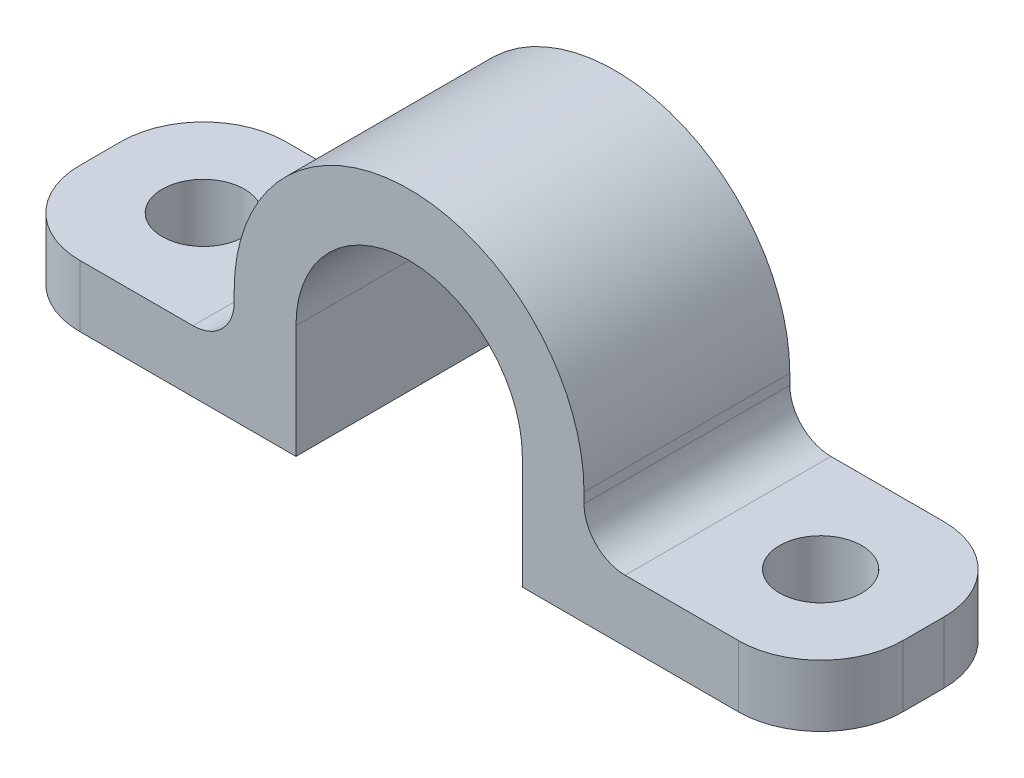
from build123d import *

# Parameters (mm, degrees)
BOSS_EXTRUDE1_DEPTH = 5
SKETCH2_R           = 2
CUT_EXTRUDE1_DEPTH  = 4
FILLET1_R           = 4
FILLET2_R           = 2


with BuildPart() as part:
    # Sketch1 → Boss-Extrude1 (new body, symmetric)
    with BuildSketch(Plane.XY):
        with BuildLine():
            Line((-5.5, -2.5), (-5.5, 0))
            ThreePointArc((-5.5, 0), (0, 5.5), (5.5, 0))
            Line((5.5, 0), (5.5, -2.5))
            Line((5.5, -2.5), (8.124038405, -2.5))
            ThreePointArc((8.124038405, -2.5), (8.405484116, -1.264055687), (8.5, 0))
            ThreePointArc((8.5, 0), (0, 8.5), (-8.5, 0))
            ThreePointArc((-8.5, 0), (-8.405484116, -1.264055687), (-8.124038405, -2.5))
            Line((-8.124038405, -2.5), (-5.5, -2.5))
        make_face()
        with BuildLine():
            Line((-5.5, -5.5), (-5.5, -2.5))
            Line((-5.5, -2.5), (-8.124038405, -2.5))
            ThreePointArc((-8.124038405, -2.5), (-7.454857018, -4.083516479), (-6.480740698, -5.5))
            Line((-6.480740698, -5.5), (-5.5, -5.5))
        make_face()
        with BuildLine():
            ThreePointArc((-6.480740698, -5.5), (-7.454857018, -4.083516479), (-8.124038405, -2.5))
            Line((-8.124038405, -2.5), (-8.5, -2.5))
            Line((-8.5, -2.5), (-20, -2.5))
            Line((-20, -2.5), (-20, -5.5))
            Line((-20, -5.5), (-6.480740698, -5.5))
        make_face()
        with BuildLine():
            Line((8.124038405, -2.5), (5.5, -2.5))
            Line((5.5, -2.5), (5.5, -5.5))
            Line((5.5, -5.5), (6.480740698, -5.5))
            ThreePointArc((6.480740698, -5.5), (7.454857018, -4.083516479), (8.124038405, -2.5))
        make_face()
        with BuildLine():
            Line((8.5, -2.5), (8.124038405, -2.5))
            ThreePointArc((8.124038405, -2.5), (7.454857018, -4.083516479), (6.480740698, -5.5))
            Line((6.480740698, -5.5), (20, -5.5))
            Line((20, -5.5), (20, -2.5))
            Line((20, -2.5), (8.5, -2.5))
        make_face()
        with BuildLine():
            ThreePointArc((8.5, 0), (8.405484116, -1.264055687), (8.124038405, -2.5))
            Line((8.124038405, -2.5), (8.5, -2.5))
            Line((8.5, -2.5), (8.5, 0))
        make_face()
        with BuildLine():
            Line((-8.5, -2.5), (-8.124038405, -2.5))
            ThreePointArc((-8.124038405, -2.5), (-8.405484116, -1.264055687), (-8.5, 0))
            Line((-8.5, 0), (-8.5, -2.5))
        make_face()
    extrude(amount=BOSS_EXTRUDE1_DEPTH, both=True)

    # Sketch2 → Cut-Extrude1 (cut, through all)
    with BuildSketch(Plane(origin=(0, -2.5, 0), x_dir=(1, 0, 0), z_dir=(0, 1, 0))):
        with Locations((-15, 0)):
            Circle(SKETCH2_R)
        with Locations((15, 0)):
            Circle(SKETCH2_R)
    extrude(amount=-CUT_EXTRUDE1_DEPTH, mode=Mode.SUBTRACT)

    # Fillet1
    fillet1_edges = [part.edges().sort_by_distance(p)[0] for p in [
        (20, -4, -5),
        (-20, -4, -5),
        (-20, -4, 5),
        (20, -4, 5),
    ]]
    fillet(fillet1_edges, radius=FILLET1_R)

    # Fillet2
    fillet2_edges = [part.edges().sort_by_distance(p)[0] for p in [
        (-8.5, -2.5, 0),
        (8.5, -2.5, 0),
    ]]
    fillet(fillet2_edges, radius=FILLET2_R)


solid = part.part
